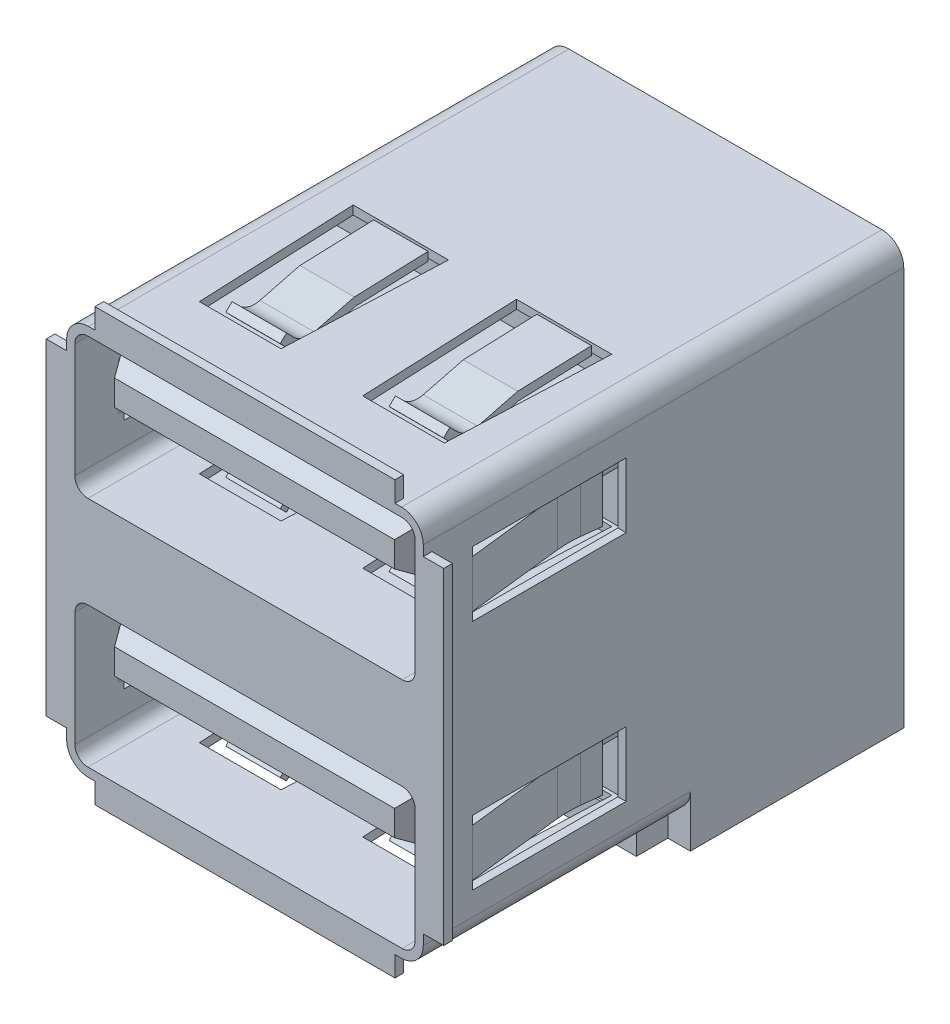
from build123d import *
from OCP.BRepFilletAPI import BRepFilletAPI_MakeChamfer

# Parameters (mm, degrees)
SKETCH1_W                                      = 13.1
SKETCH1_H                                      = 17.65
BASE_DEPTH                                     = 14.35
SKETCH3_W                                      = 11.02
SKETCH3_H                                      = 0.75
SKETCH3_W_2                                    = 0.75
SKETCH3_H_2                                    = 12
FRONT_TABS_DEPTH                               = 0.32
CORNER_FILLETS_R                               = 0.8
D_BACK_STEP_DEPTH                              = 7.84
SKETCH19_W                                     = 11.45
SKETCH19_H                                     = 1.16
D_BOTTOM_STEP_DEPTH                            = 1.1
CONTACT_AREA_CUTOUT_DEPTH                      = 8.85
TOP_BOTTOM_FLANGE_CUTOUT_DEPTH                 = 5.8
TOP_BOTTOM_FLANGE_DEPTH                        = 1
TOP_BOTTOM_FLANGE_PATTERN_COUNT                = 2
TOP_BOTTOM_FLANGE_PATTERN_PITCH                = 6
SKETCH14_W                                     = 5.65
SKETCH14_H                                     = 2.38
SIDE_FLANGE_CUTOUT_DEPTH                       = 23.30948509
SIDE_FLANGE_DEPTH                              = 0.875
SKETCH16_W                                     = 11.15
SKETCH16_H                                     = 1.8
CONTACT_GUIDE_DEPTH                            = 8.5
CONTACT_GUIDE_LEAD_IN_SIZE                     = 0.75
CONTACT_GUIDE_LEAD_IN_SIZE2                    = 0.433012702
CONTACT_DEPTH                                  = 0.33
CONTACT_PATTERN_COUNT                          = 2
CONTACT_PATTERN_PITCH                          = 2.5
CONTACT_PATTERN_MIRROR_COPY_1_DEPTH            = 0.33
TOP_USB_PATTERN_COUNT                          = 2
TOP_USB_PATTERN_PITCH                          = 8.55
TOP_USB_PATTERN_COPY_1_DEPTH                   = 1
TOP_USB_PATTERN_COPY_2_DEPTH                   = 0.33
TOP_USB_PATTERN_COPY_3_DEPTH                   = 0.33
TOP_USB_PATTERN_COPY_4_DEPTH                   = 0.33
CONTACT_GUIDE_LEAD_IN_OF_TOP_USB_PATTERN_SIZE  = 0.75
CONTACT_GUIDE_LEAD_IN_OF_TOP_USB_PATTERN_SIZE2 = 0.433012702


with BuildPart() as part:
    # Sketch1 → Base (new body)
    with BuildSketch(Plane(origin=(0, 0, 0), x_dir=(1, 0, 0), z_dir=(0, 1, 0))):
        Rectangle(SKETCH1_W, SKETCH1_H)
    extrude(amount=BASE_DEPTH)

    # Sketch3 → Front Tabs (add)
    with BuildSketch(Plane.XY.offset(8.825)):
        with Locations((0, 14.725)):
            Rectangle(SKETCH3_W, SKETCH3_H)
        with Locations((6.925, 7.175)):
            Rectangle(SKETCH3_W_2, SKETCH3_H_2)
        with Locations((0, -0.375)):
            Rectangle(SKETCH3_W, SKETCH3_H)
        with Locations((-6.925, 7.175)):
            Rectangle(SKETCH3_W_2, SKETCH3_H_2)
    extrude(amount=-FRONT_TABS_DEPTH)

    # Corner Fillets
    corner_fillets_edges = [part.edges().sort_by_distance(p)[0] for p in [
        (-6.55, 14.35, 0),
        (-6.55, 0, 0),
        (6.55, 0, 0),
        (6.55, 14.35, 0),
    ]]
    fillet(corner_fillets_edges, radius=CORNER_FILLETS_R)

    # Sketch18 → -D Back Step (add)
    with BuildSketch(Plane(origin=(0, 0, -8.825), x_dir=(-1, 0, 0), z_dir=(0, 0, -1))):
        with BuildLine():
            Line((-6.55, 0.8), (-6.55, -1.1))
            Line((-6.55, -1.1), (6.55, -1.1))
            Line((6.55, -1.1), (6.55, 0.8))
            ThreePointArc((6.55, 0.8), (6.315685425, 0.234314575), (5.75, 0))
            Line((5.75, 0), (-5.75, 0))
            ThreePointArc((-5.75, 0), (-6.315685425, 0.234314575), (-6.55, 0.8))
        make_face()
    extrude(amount=-D_BACK_STEP_DEPTH)

    # Sketch19 → -D Bottom Step (add)
    with BuildSketch(Plane.XZ):
        with Locations((0, -0.405)):
            Rectangle(SKETCH19_W, SKETCH19_H)
    extrude(amount=D_BOTTOM_STEP_DEPTH)

    # Sketch8 → Contact Area Cutout (cut)
    with BuildSketch(Plane.XY.offset(8.825)):
        with BuildLine():
            Line((-6.25, 5), (-6.25, 0.8))
            ThreePointArc((-6.25, 0.8), (-6.109411255, 0.460588745), (-5.77, 0.32))
            Line((-5.77, 0.32), (5.77, 0.32))
            ThreePointArc((5.77, 0.32), (6.109411255, 0.460588745), (6.25, 0.8))
            Line((6.25, 0.8), (6.25, 5))
            ThreePointArc((6.25, 5), (6.109411255, 5.339411255), (5.77, 5.48))
            Line((5.77, 5.48), (-5.77, 5.48))
            ThreePointArc((-5.77, 5.48), (-6.109411255, 5.339411255), (-6.25, 5))
        make_face()
    contact_area_cutout = extrude(amount=-CONTACT_AREA_CUTOUT_DEPTH, mode=Mode.SUBTRACT)

    # Sketch12 → Top/Bottom Flange Cutout (cut)
    with BuildSketch(Plane(origin=(0, 0, 0), x_dir=(-1, 0, 0), z_dir=(0, 1, 0))):
        Polygon((4.5, 6), (4.75, 0.1), (1.25, 0.1), (1.5, 6), align=None)
        Polygon((-4.75, 0.1), (-1.25, 0.1), (-1.5, 6), (-4.5, 6), align=None)
    top_bottom_flange_cutout = extrude(amount=TOP_BOTTOM_FLANGE_CUTOUT_DEPTH, mode=Mode.SUBTRACT)

    # Sketch13 → Top/Bottom Flange (add, symmetric)
    with BuildSketch(Plane(origin=(-3, 0, 0), x_dir=(0, 0, -1), z_dir=(1, 0, 0))):
        with BuildLine():
            Line((-2.760063847, 0.417489088), (-4.198269078, 0.784212886))
            ThreePointArc((-4.198269078, 0.784212886), (-4.778069903, 0.777154214), (-5.276638422, 0.481099735))
            Line((-5.276638422, 0.481099735), (-5.529039549, 0.222413302))
            Line((-5.529039549, 0.222413302), (-5.3, -0.001061272))
            Line((-5.3, -0.001061272), (-5.047598873, 0.257625162))
            ThreePointArc((-5.047598873, 0.257625162), (-4.691478502, 0.469092647), (-4.277335056, 0.474134555))
            Line((-4.277335056, 0.474134555), (-2.8059045, 0.098938728))
            Line((-2.8059045, 0.098938728), (-0.1, 0.001))
            Line((-0.1, 0.001), (-0.1, 0.321209538))
            Line((-0.1, 0.321209538), (-2.760063847, 0.417489088))
        make_face()
        with BuildLine():
            Line((-2.8059045, 5.601061272), (-4.277335056, 5.225865445))
            ThreePointArc((-4.277335056, 5.225865445), (-4.691478502, 5.230907353), (-5.047598873, 5.442374838))
            Line((-5.047598873, 5.442374838), (-5.3, 5.701061272))
            Line((-5.3, 5.701061272), (-5.529039549, 5.477586698))
            Line((-5.529039549, 5.477586698), (-5.276638422, 5.218900265))
            ThreePointArc((-5.276638422, 5.218900265), (-4.778069903, 4.922845786), (-4.198269078, 4.915787114))
            Line((-4.198269078, 4.915787114), (-2.760063847, 5.282510912))
            Line((-2.760063847, 5.282510912), (-0.1, 5.378790462))
            Line((-0.1, 5.378790462), (-0.1, 5.699))
            Line((-0.1, 5.699), (-2.8059045, 5.601061272))
        make_face()
    top_bottom_flange = extrude(amount=TOP_BOTTOM_FLANGE_DEPTH, both=True)

    # Top/Bottom Flange Pattern: Top/Bottom Flange ×2
    with Locations(*[(i * TOP_BOTTOM_FLANGE_PATTERN_PITCH, 0, 0) for i in range(1, TOP_BOTTOM_FLANGE_PATTERN_COUNT)]):
        add(top_bottom_flange)

    # Sketch14 → Side Flange Cutout (cut, through all)
    with BuildSketch(Plane(origin=(6.55, 0, 0), x_dir=(0, 0, -1), z_dir=(1, 0, 0))):
        with Locations((-4.2, 2.85)):
            Rectangle(SKETCH14_W, SKETCH14_H)
    side_flange_cutout = extrude(amount=-SIDE_FLANGE_CUTOUT_DEPTH, mode=Mode.SUBTRACT)

    # Sketch15 → Side Flange (add, symmetric)
    with BuildSketch(Plane(origin=(0, 2.85, 0), x_dir=(-1, 0, 0), z_dir=(0, 1, 0))):
        with BuildLine():
            Line((6.55, 7.025), (6.149012428, 3.498694006))
            ThreePointArc((6.149012428, 3.498694006), (6.125000079, 3.075770202), (6.148838699, 2.65283657))
            Line((6.148838699, 2.65283657), (6.231300503, 1.925))
            Line((6.231300503, 1.925), (5.913334739, 1.888975387))
            Line((5.913334739, 1.888975387), (5.830872935, 2.616811958))
            ThreePointArc((5.830872935, 2.616811958), (5.805000086, 3.075835926), (5.831061488, 3.534849227))
            Line((5.831061488, 3.534849227), (6.25, 7.219016737))
            Line((6.25, 7.219016737), (6.55, 7.025))
        make_face()
        with BuildLine():
            Line((-5.913334739, 1.888975387), (-6.231300503, 1.925))
            Line((-6.231300503, 1.925), (-6.148838699, 2.65283657))
            ThreePointArc((-6.148838699, 2.65283657), (-6.125000079, 3.075770202), (-6.149012428, 3.498694006))
            Line((-6.149012428, 3.498694006), (-6.55, 7.025))
            Line((-6.55, 7.025), (-6.25, 7.219016737))
            Line((-6.25, 7.219016737), (-5.831061488, 3.534849227))
            ThreePointArc((-5.831061488, 3.534849227), (-5.805000086, 3.075835926), (-5.830872935, 2.616811958))
            Line((-5.830872935, 2.616811958), (-5.913334739, 1.888975387))
        make_face()
    side_flange = extrude(amount=SIDE_FLANGE_DEPTH, both=True)

    # Sketch16 → Contact Guide (add)
    with BuildSketch(Plane.XY.offset(-0.025)):
        with Locations((0, 3.82)):
            Rectangle(SKETCH16_W, SKETCH16_H)
    contact_guide = extrude(amount=CONTACT_GUIDE_DEPTH)

    # Contact Guide Lead-in: one chamfer whose edges measure the first distance from different faces: ONE call of the kernel's chamfer builder (chamfer() names one face for all edges)
    contact_guide_lead_in_edges_1 = [part.edges().sort_by_distance(p)[0] for p in [
        (5.575, 3.82, 8.475),
    ]]
    contact_guide_lead_in_side_1 = [part.faces().sort_by_distance(p)[0] for p in [
        (5.575, 3.82, 4.225),
    ]]
    contact_guide_lead_in_edges_2 = [part.edges().sort_by_distance(p)[0] for p in [
        (0, 4.72, 8.475),
    ]]
    contact_guide_lead_in_side_2 = [part.faces().sort_by_distance(p)[0] for p in [
        (0, 4.72, 4.225),
    ]]
    contact_guide_lead_in_edges_3 = [part.edges().sort_by_distance(p)[0] for p in [
        (-5.575, 3.82, 8.475),
    ]]
    contact_guide_lead_in_side_3 = [part.faces().sort_by_distance(p)[0] for p in [
        (-5.575, 3.82, 4.225),
    ]]
    contact_guide_lead_in_edges_4 = [part.edges().sort_by_distance(p)[0] for p in [
        (0, 2.92, 8.475),
    ]]
    contact_guide_lead_in_side_4 = [part.faces().sort_by_distance(p)[0] for p in [
        (0, 2.92, 4.225),
    ]]
    contact_guide_lead_in = BRepFilletAPI_MakeChamfer(part.part.solid().wrapped)
    for e in contact_guide_lead_in_edges_1:
        contact_guide_lead_in.Add(CONTACT_GUIDE_LEAD_IN_SIZE, CONTACT_GUIDE_LEAD_IN_SIZE2, e.wrapped, contact_guide_lead_in_side_1[0].wrapped)  # the first distance lies on this face
    for e in contact_guide_lead_in_edges_2:
        contact_guide_lead_in.Add(CONTACT_GUIDE_LEAD_IN_SIZE, CONTACT_GUIDE_LEAD_IN_SIZE2, e.wrapped, contact_guide_lead_in_side_2[0].wrapped)  # the first distance lies on this face
    for e in contact_guide_lead_in_edges_3:
        contact_guide_lead_in.Add(CONTACT_GUIDE_LEAD_IN_SIZE, CONTACT_GUIDE_LEAD_IN_SIZE2, e.wrapped, contact_guide_lead_in_side_3[0].wrapped)  # the first distance lies on this face
    for e in contact_guide_lead_in_edges_4:
        contact_guide_lead_in.Add(CONTACT_GUIDE_LEAD_IN_SIZE, CONTACT_GUIDE_LEAD_IN_SIZE2, e.wrapped, contact_guide_lead_in_side_4[0].wrapped)  # the first distance lies on this face
    add(Compound.cast(contact_guide_lead_in.Shape()), mode=Mode.REPLACE)

    # Sketch17 → Contact (add, symmetric)
    with BuildSketch(Plane(origin=(-3.5, 0, 0), x_dir=(0, 0, -1), z_dir=(1, 0, 0))):
        with BuildLine():
            Line((0.025, 3.91), (0.025, 3.65))
            Line((0.025, 3.65), (-1.225, 3.65))
            Line((-1.225, 3.65), (-4.787949724, 2.507463672))
            ThreePointArc((-4.787949724, 2.507463672), (-5.767552697, 2.419100424), (-6.691249642, 2.757056047))
            Line((-6.691249642, 2.757056047), (-7.225, 3.1))
            Line((-7.225, 3.1), (-7.084455597, 3.31874019))
            Line((-7.084455597, 3.31874019), (-6.550705239, 2.975796237))
            ThreePointArc((-6.550705239, 2.975796237), (-5.733746608, 2.676893264), (-4.867342201, 2.755045647))
            Line((-4.867342201, 2.755045647), (-1.265667409, 3.91))
            Line((-1.265667409, 3.91), (0.025, 3.91))
        make_face()
    contact = extrude(amount=CONTACT_DEPTH, both=True)

    # Contact Pattern: Contact ×2
    with Locations(*[(i * CONTACT_PATTERN_PITCH, 0, 0) for i in range(1, CONTACT_PATTERN_COUNT)]):
        add(contact)

    # Contact Pattern Mirror: Contact across plane
    add(contact.mirror(Plane(origin=(0, 0, 0), x_dir=(0, 0, 1), z_dir=(1, 0, 0))))

    # Contact Pattern Mirror copy 1 sketch → Contact Pattern Mirror copy 1 (add, symmetric)
    with BuildSketch(Plane(origin=(1, 0, 0), x_dir=(0, 0, -1), z_dir=(-1, 0, 0))):
        with BuildLine():
            Line((0.025, -3.91), (0.025, -3.65))
            Line((0.025, -3.65), (-1.225, -3.65))
            Line((-1.225, -3.65), (-4.787949724, -2.507463672))
            ThreePointArc((-4.787949724, -2.507463672), (-5.767552697, -2.419100424), (-6.691249642, -2.757056047))
            Line((-6.691249642, -2.757056047), (-7.225, -3.1))
            Line((-7.225, -3.1), (-7.084455597, -3.31874019))
            Line((-7.084455597, -3.31874019), (-6.550705239, -2.975796237))
            ThreePointArc((-6.550705239, -2.975796237), (-5.733746608, -2.676893264), (-4.867342201, -2.755045647))
            Line((-4.867342201, -2.755045647), (-1.265667409, -3.91))
            Line((-1.265667409, -3.91), (0.025, -3.91))
        make_face()
    extrude(amount=CONTACT_PATTERN_MIRROR_COPY_1_DEPTH, both=True)

    # Top USB Pattern: Contact Area Cutout, Top/Bottom Flange Cutout, Top/Bottom Flange, Side Flange Cutout, Side Flange, Contact Guide, Contact ×2
    with Locations(*[(0, i * TOP_USB_PATTERN_PITCH, 0) for i in range(1, TOP_USB_PATTERN_COUNT)]):
        add(contact_area_cutout, mode=Mode.SUBTRACT)
        add(top_bottom_flange_cutout, mode=Mode.SUBTRACT)
        add(top_bottom_flange)
        add(side_flange_cutout, mode=Mode.SUBTRACT)
        add(side_flange)
        add(contact_guide)
        add(contact)

    # Top USB Pattern copy 1 sketch → Top USB Pattern copy 1 (add, symmetric)
    with BuildSketch(Plane(origin=(3, 8.55, 0), x_dir=(0, 0, -1), z_dir=(1, 0, 0))):
        with BuildLine():
            Line((-2.760063847, 0.417489088), (-4.198269078, 0.784212886))
            ThreePointArc((-4.198269078, 0.784212886), (-4.778069903, 0.777154214), (-5.276638422, 0.481099735))
            Line((-5.276638422, 0.481099735), (-5.529039549, 0.222413302))
            Line((-5.529039549, 0.222413302), (-5.3, -0.001061272))
            Line((-5.3, -0.001061272), (-5.047598873, 0.257625162))
            ThreePointArc((-5.047598873, 0.257625162), (-4.691478502, 0.469092647), (-4.277335056, 0.474134555))
            Line((-4.277335056, 0.474134555), (-2.8059045, 0.098938728))
            Line((-2.8059045, 0.098938728), (-0.1, 0.001))
            Line((-0.1, 0.001), (-0.1, 0.321209538))
            Line((-0.1, 0.321209538), (-2.760063847, 0.417489088))
        make_face()
        with BuildLine():
            Line((-2.8059045, 5.601061272), (-4.277335056, 5.225865445))
            ThreePointArc((-4.277335056, 5.225865445), (-4.691478502, 5.230907353), (-5.047598873, 5.442374838))
            Line((-5.047598873, 5.442374838), (-5.3, 5.701061272))
            Line((-5.3, 5.701061272), (-5.529039549, 5.477586698))
            Line((-5.529039549, 5.477586698), (-5.276638422, 5.218900265))
            ThreePointArc((-5.276638422, 5.218900265), (-4.778069903, 4.922845786), (-4.198269078, 4.915787114))
            Line((-4.198269078, 4.915787114), (-2.760063847, 5.282510912))
            Line((-2.760063847, 5.282510912), (-0.1, 5.378790462))
            Line((-0.1, 5.378790462), (-0.1, 5.699))
            Line((-0.1, 5.699), (-2.8059045, 5.601061272))
        make_face()
    extrude(amount=TOP_USB_PATTERN_COPY_1_DEPTH, both=True)

    # Top USB Pattern copy 2 sketch → Top USB Pattern copy 2 (add, symmetric)
    with BuildSketch(Plane(origin=(-1, 8.55, 0), x_dir=(0, 0, -1), z_dir=(1, 0, 0))):
        with BuildLine():
            Line((0.025, 3.91), (0.025, 3.65))
            Line((0.025, 3.65), (-1.225, 3.65))
            Line((-1.225, 3.65), (-4.787949724, 2.507463672))
            ThreePointArc((-4.787949724, 2.507463672), (-5.767552697, 2.419100424), (-6.691249642, 2.757056047))
            Line((-6.691249642, 2.757056047), (-7.225, 3.1))
            Line((-7.225, 3.1), (-7.084455597, 3.31874019))
            Line((-7.084455597, 3.31874019), (-6.550705239, 2.975796237))
            ThreePointArc((-6.550705239, 2.975796237), (-5.733746608, 2.676893264), (-4.867342201, 2.755045647))
            Line((-4.867342201, 2.755045647), (-1.265667409, 3.91))
            Line((-1.265667409, 3.91), (0.025, 3.91))
        make_face()
    extrude(amount=TOP_USB_PATTERN_COPY_2_DEPTH, both=True)

    # Top USB Pattern copy 3 sketch → Top USB Pattern copy 3 (add, symmetric)
    with BuildSketch(Plane(origin=(3.5, 8.55, 0), x_dir=(0, 0, -1), z_dir=(-1, 0, 0))):
        with BuildLine():
            Line((0.025, -3.91), (0.025, -3.65))
            Line((0.025, -3.65), (-1.225, -3.65))
            Line((-1.225, -3.65), (-4.787949724, -2.507463672))
            ThreePointArc((-4.787949724, -2.507463672), (-5.767552697, -2.419100424), (-6.691249642, -2.757056047))
            Line((-6.691249642, -2.757056047), (-7.225, -3.1))
            Line((-7.225, -3.1), (-7.084455597, -3.31874019))
            Line((-7.084455597, -3.31874019), (-6.550705239, -2.975796237))
            ThreePointArc((-6.550705239, -2.975796237), (-5.733746608, -2.676893264), (-4.867342201, -2.755045647))
            Line((-4.867342201, -2.755045647), (-1.265667409, -3.91))
            Line((-1.265667409, -3.91), (0.025, -3.91))
        make_face()
    extrude(amount=TOP_USB_PATTERN_COPY_3_DEPTH, both=True)

    # Top USB Pattern copy 4 sketch → Top USB Pattern copy 4 (add, symmetric)
    with BuildSketch(Plane(origin=(1, 8.55, 0), x_dir=(0, 0, -1), z_dir=(-1, 0, 0))):
        with BuildLine():
            Line((0.025, -3.91), (0.025, -3.65))
            Line((0.025, -3.65), (-1.225, -3.65))
            Line((-1.225, -3.65), (-4.787949724, -2.507463672))
            ThreePointArc((-4.787949724, -2.507463672), (-5.767552697, -2.419100424), (-6.691249642, -2.757056047))
            Line((-6.691249642, -2.757056047), (-7.225, -3.1))
            Line((-7.225, -3.1), (-7.084455597, -3.31874019))
            Line((-7.084455597, -3.31874019), (-6.550705239, -2.975796237))
            ThreePointArc((-6.550705239, -2.975796237), (-5.733746608, -2.676893264), (-4.867342201, -2.755045647))
            Line((-4.867342201, -2.755045647), (-1.265667409, -3.91))
            Line((-1.265667409, -3.91), (0.025, -3.91))
        make_face()
    extrude(amount=TOP_USB_PATTERN_COPY_4_DEPTH, both=True)

    # Contact Guide Lead-in of Top USB Pattern: one chamfer whose edges measure the first distance from different faces: ONE call of the kernel's chamfer builder (chamfer() names one face for all edges)
    contact_guide_lead_in_of_top_usb_pattern_edges_1 = [part.edges().sort_by_distance(p)[0] for p in [
        (5.575, 12.37, 8.475),
    ]]
    contact_guide_lead_in_of_top_usb_pattern_side_1 = [part.faces().sort_by_distance(p)[0] for p in [
        (5.575, 12.37, 4.225),
    ]]
    contact_guide_lead_in_of_top_usb_pattern_edges_2 = [part.edges().sort_by_distance(p)[0] for p in [
        (0, 13.27, 8.475),
    ]]
    contact_guide_lead_in_of_top_usb_pattern_side_2 = [part.faces().sort_by_distance(p)[0] for p in [
        (0, 13.27, 4.225),
    ]]
    contact_guide_lead_in_of_top_usb_pattern_edges_3 = [part.edges().sort_by_distance(p)[0] for p in [
        (-5.575, 12.37, 8.475),
    ]]
    contact_guide_lead_in_of_top_usb_pattern_side_3 = [part.faces().sort_by_distance(p)[0] for p in [
        (-5.575, 12.37, 4.225),
    ]]
    contact_guide_lead_in_of_top_usb_pattern_edges_4 = [part.edges().sort_by_distance(p)[0] for p in [
        (0, 11.47, 8.475),
    ]]
    contact_guide_lead_in_of_top_usb_pattern_side_4 = [part.faces().sort_by_distance(p)[0] for p in [
        (0, 11.47, 4.225),
    ]]
    contact_guide_lead_in_of_top_usb_pattern = BRepFilletAPI_MakeChamfer(part.part.solid().wrapped)
    for e in contact_guide_lead_in_of_top_usb_pattern_edges_1:
        contact_guide_lead_in_of_top_usb_pattern.Add(CONTACT_GUIDE_LEAD_IN_OF_TOP_USB_PATTERN_SIZE, CONTACT_GUIDE_LEAD_IN_OF_TOP_USB_PATTERN_SIZE2, e.wrapped, contact_guide_lead_in_of_top_usb_pattern_side_1[0].wrapped)  # the first distance lies on this face
    for e in contact_guide_lead_in_of_top_usb_pattern_edges_2:
        contact_guide_lead_in_of_top_usb_pattern.Add(CONTACT_GUIDE_LEAD_IN_OF_TOP_USB_PATTERN_SIZE, CONTACT_GUIDE_LEAD_IN_OF_TOP_USB_PATTERN_SIZE2, e.wrapped, contact_guide_lead_in_of_top_usb_pattern_side_2[0].wrapped)  # the first distance lies on this face
    for e in contact_guide_lead_in_of_top_usb_pattern_edges_3:
        contact_guide_lead_in_of_top_usb_pattern.Add(CONTACT_GUIDE_LEAD_IN_OF_TOP_USB_PATTERN_SIZE, CONTACT_GUIDE_LEAD_IN_OF_TOP_USB_PATTERN_SIZE2, e.wrapped, contact_guide_lead_in_of_top_usb_pattern_side_3[0].wrapped)  # the first distance lies on this face
    for e in contact_guide_lead_in_of_top_usb_pattern_edges_4:
        contact_guide_lead_in_of_top_usb_pattern.Add(CONTACT_GUIDE_LEAD_IN_OF_TOP_USB_PATTERN_SIZE, CONTACT_GUIDE_LEAD_IN_OF_TOP_USB_PATTERN_SIZE2, e.wrapped, contact_guide_lead_in_of_top_usb_pattern_side_4[0].wrapped)  # the first distance lies on this face
    add(Compound.cast(contact_guide_lead_in_of_top_usb_pattern.Shape()), mode=Mode.REPLACE)


solid = part.part
